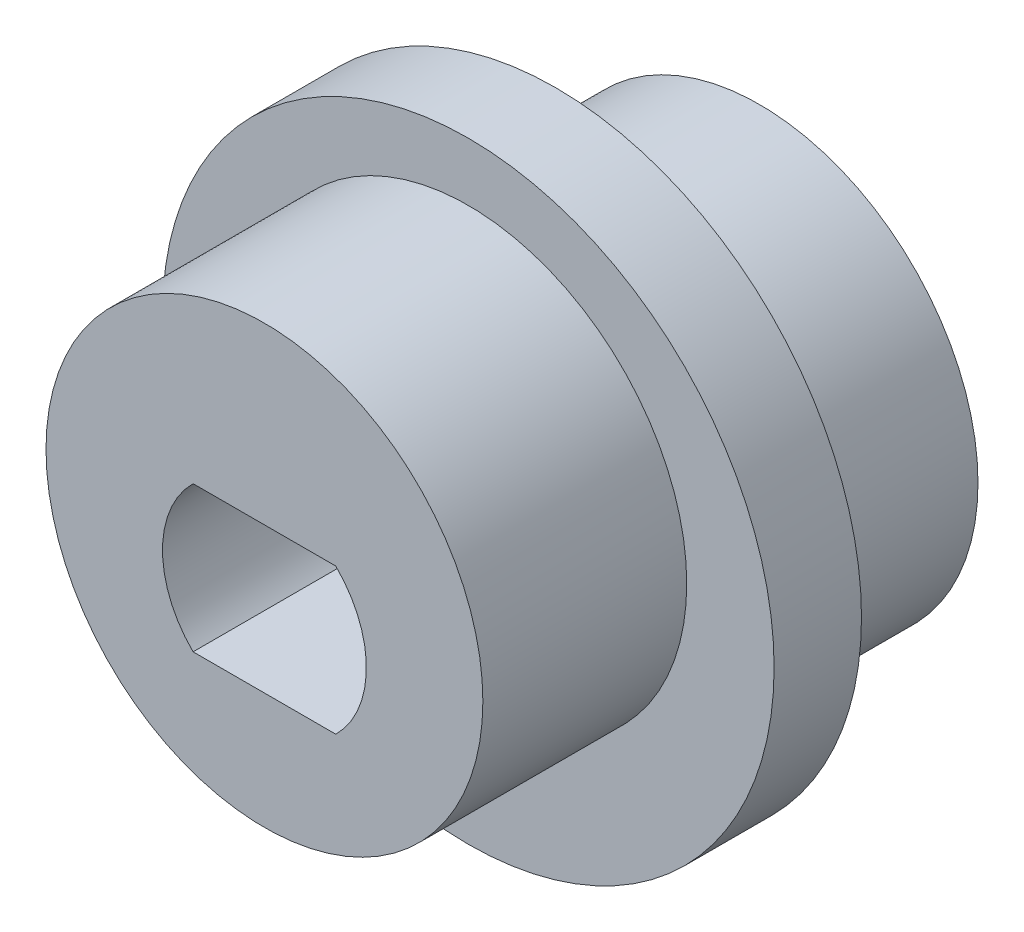
from build123d import *

# Parameters (mm, degrees)
SKETCH1_R               = 7.5
BOSS_EXTRUDE1_DEPTH     = 7
SKETCH2_R               = 8.5
BOSS_EXTRUDE2_DEPTH     = 3
SKETCH3_R               = 7.5
BOSS_EXTRUDE3_DEPTH     = 7
CUT_EXTRUDE3_DEPTH      = 8
CUT_EXTRUDE3_DEPTH_BACK = 11
SKETCH7_R               = 10.5
SKETCH7_R_2             = 8.5
BOSS_EXTRUDE4_DEPTH     = 3


with BuildPart() as part:
    # Sketch1 → Boss-Extrude1 (new body)
    with BuildSketch(Plane.XY):
        Circle(SKETCH1_R)
    extrude(amount=BOSS_EXTRUDE1_DEPTH)

    # Sketch2 → Boss-Extrude2 (add)
    with BuildSketch(Plane.XY.offset(7)):
        with Locations((0, 1)):
            Circle(SKETCH2_R)
    extrude(amount=BOSS_EXTRUDE2_DEPTH)

    # Sketch3 → Boss-Extrude3 (add)
    with BuildSketch(Plane.XY.offset(10)):
        with Locations((0, 2)):
            Circle(SKETCH3_R)
    extrude(amount=BOSS_EXTRUDE3_DEPTH)

    # Sketch6 → Cut-Extrude3 (cut, two sides)
    with BuildSketch(Plane.XY.offset(10)) as cut_extrude3_sk:
        with BuildLine():
            Line((-2.449489743, 3.5), (2.449489743, 3.5))
            ThreePointArc((2.449489743, 3.5), (3.5, 1), (2.449489743, -1.5))
            Line((2.449489743, -1.5), (-2.449489743, -1.5))
            ThreePointArc((-2.449489743, -1.5), (-3.5, 1), (-2.449489743, 3.5))
        make_face()
    extrude(amount=CUT_EXTRUDE3_DEPTH, mode=Mode.SUBTRACT)
    extrude(cut_extrude3_sk.sketch, amount=-CUT_EXTRUDE3_DEPTH_BACK, mode=Mode.SUBTRACT)

    # Sketch7 → Boss-Extrude4 (add)
    with BuildSketch(Plane.XY.offset(10)):
        with Locations((0, 1)):
            Circle(SKETCH7_R)
        with Locations((0, 1)):
            Circle(SKETCH7_R_2, mode=Mode.SUBTRACT)
    extrude(amount=-BOSS_EXTRUDE4_DEPTH)


solid = part.part
